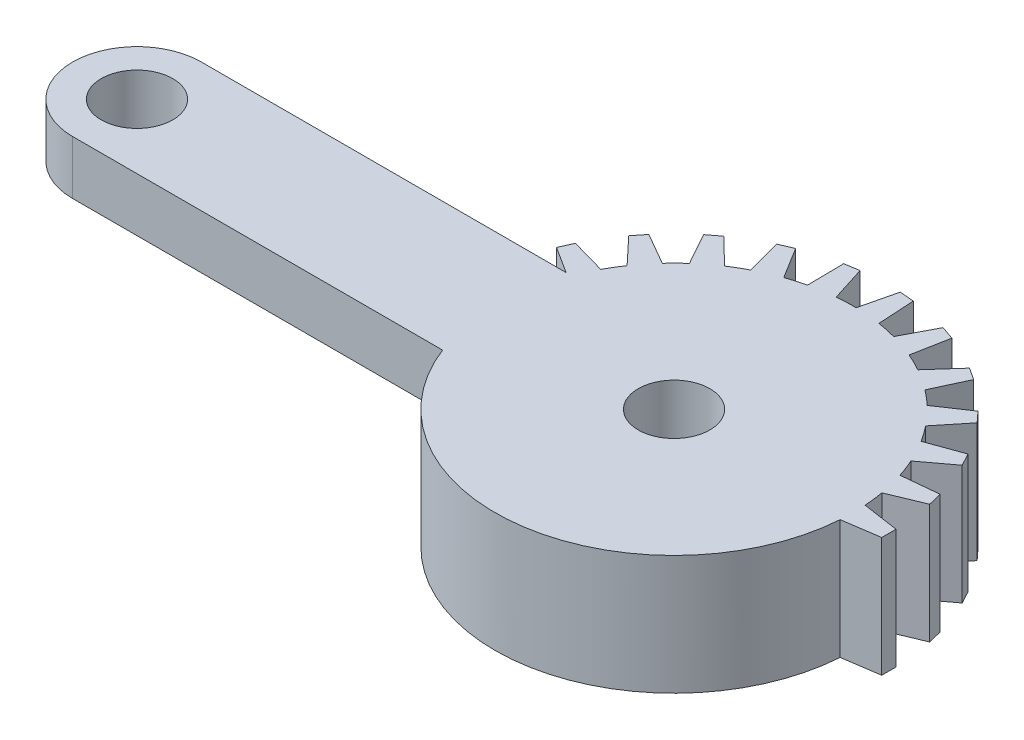
from build123d import *

# Parameters (mm, degrees)
BOSS_EXTRUDE1_DEPTH = 33.333333333
BOSS_EXTRUDE2_DEPTH = 33.333333
CIRPATTERN2_COUNT   = 13
CIRPATTERN2_ANGLE   = 170
F_20_0MM_1_D        = 20
SCALE_1_SCALE       = 0.3
CUT_EXTRUDE_START   = -4.5
CUT_EXTRUDE_1_DEPTH = 5.5


with BuildPart() as part:
    # Sketch1 → Boss-Extrude1 (new body)
    with BuildSketch(Plane(origin=(0, 0, 0), x_dir=(1, 0, 0), z_dir=(0, 1, 0))):
        with BuildLine():
            Line((-150, 18), (-46.647615159, 18))
            ThreePointArc((-46.647615159, 18), (50, 0), (-46.647615159, -18))
            Line((-46.647615159, -18), (-150, -18))
            ThreePointArc((-150, -18), (-168, 0), (-150, 18))
        make_face()
    extrude(amount=BOSS_EXTRUDE1_DEPTH)

    # Sketch2 → Boss-Extrude2 (add)
    with BuildSketch(Plane(origin=(0, 33.333333333, 0), x_dir=(1, 0, 0), z_dir=(0, 1, 0))):
        Polygon((49.877349569, 3.5), (60, 2), (60, -2), (49.877349569, -3.5), (50, 0), align=None)
    boss_extrude2 = extrude(amount=-BOSS_EXTRUDE2_DEPTH)

    # CirPattern2: Boss-Extrude2 ×13 about axis
    cirpattern2_axis = Axis((0, 0, 0), (0, 1, 0))
    for i in range(1, CIRPATTERN2_COUNT):
        add(boss_extrude2.rotate(cirpattern2_axis, i * CIRPATTERN2_ANGLE / (CIRPATTERN2_COUNT - 1)))

    # Ø20.0mm 맞춤핀 구멍1 (through all)
    with Locations(Plane(origin=(0, 33.333333333, 0), x_dir=(1, 0, 0), z_dir=(0, 1, 0))):
        with Locations((-150, 0), (0, 0)):
            Hole(F_20_0MM_1_D / 2)


with BuildPart() as part_1:
    # 축척1: scaled about (-32.40075302, 16.666666686, -1.971262619)
    add(part.part.scale(SCALE_1_SCALE).moved(Location((-22.680527114, 11.66666668, -1.379883833))))

    # 스케치1 → 컷-돌출1 (cut)
    with BuildSketch(Plane(origin=(0, 21.666666667, 0), x_dir=(1, 0, 0), z_dir=(0, 1, 0)).offset(CUT_EXTRUDE_START)):
        with BuildLine():
            Line((-36.6748116, -4.020116137), (-67.680527053, -4.020116137))
            ThreePointArc((-67.680527053, -4.020116137), (-73.080527053, 1.379883863), (-67.680527053, 6.779883863))
            Line((-67.680527053, 6.779883863), (-36.6748116, 6.779883863))
            ThreePointArc((-36.6748116, 6.779883863), (-37.680527053, 1.379883863), (-36.6748116, -4.020116137))
        make_face()
    extrude(amount=-CUT_EXTRUDE_1_DEPTH, mode=Mode.SUBTRACT)


solid = part_1.part
